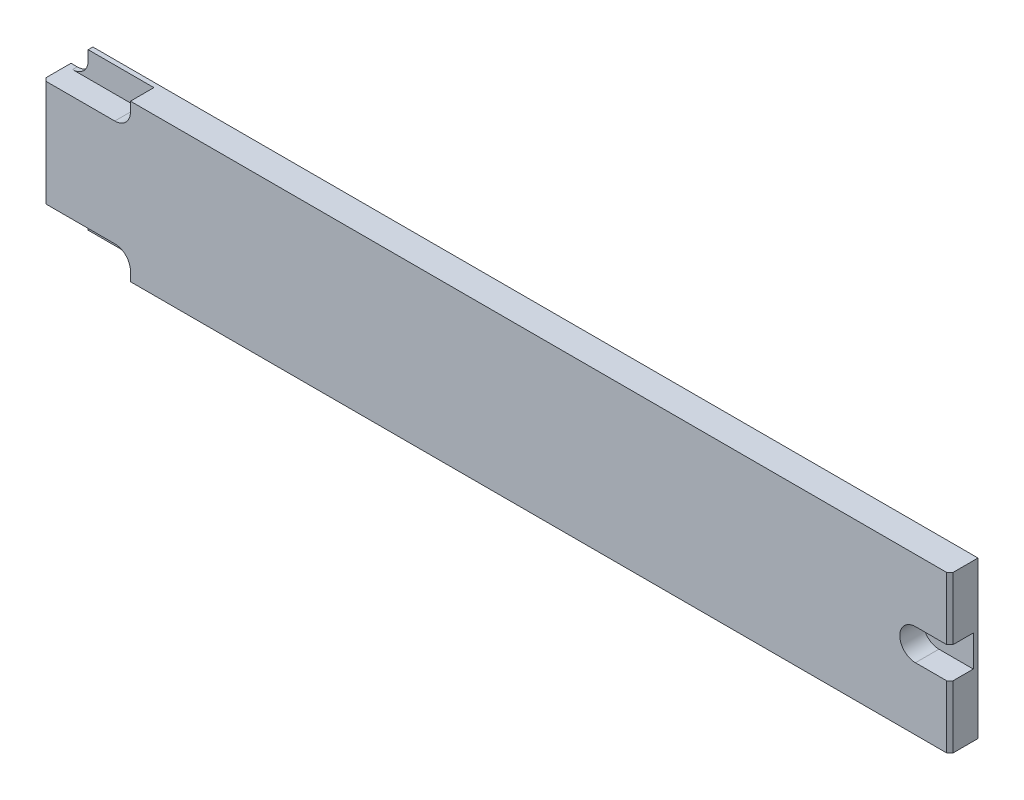
from build123d import *

# Parameters (mm, degrees)
BASE_EXTRUDE_DEPTH = 9
CUT_EXTRUDE1_DEPTH = 7.5
CHAMFER1_SIZE      = 1


with BuildPart() as part:
    # Sketch1 → Base-Extrude (new body)
    with BuildSketch(Plane.XY):
        with BuildLine():
            Line((7, 0), (290, 0))
            Line((290, 0), (290, 50))
            Line((290, 50), (7, 50))
            Line((7, 50), (7, 47))
            ThreePointArc((7, 47), (5.535533906, 43.464466094), (2, 42))
            Line((2, 42), (0, 42))
            Line((0, 42), (0, 8))
            Line((0, 8), (2, 8))
            ThreePointArc((2, 8), (5.535533906, 6.535533906), (7, 3))
            Line((7, 3), (7, 0))
        make_face()
    extrude(amount=BASE_EXTRUDE_DEPTH)

    # Sketch2 → Cut-Extrude1 (cut)
    with BuildSketch(Plane.XY.offset(9)):
        with BuildLine():
            Line((2, 8), (23, 8))
            ThreePointArc((23, 8), (26.535533906, 6.535533906), (28, 3))
            Line((28, 3), (28, 0))
            Line((28, 0), (2, 0))
            Line((2, 0), (2, 8))
        make_face()
        with BuildLine():
            Line((279, 30), (290, 30))
            Line((290, 30), (290, 20))
            Line((290, 20), (279, 20))
            ThreePointArc((279, 20), (274, 25), (279, 30))
        make_face()
        with BuildLine():
            Line((28, 47), (28, 50))
            Line((28, 50), (2, 50))
            Line((2, 50), (2, 42))
            Line((2, 42), (23, 42))
            ThreePointArc((23, 42), (26.535533906, 43.464466094), (28, 47))
        make_face()
    extrude(amount=-CUT_EXTRUDE1_DEPTH, mode=Mode.SUBTRACT)

    # Chamfer1
    chamfer1_edges = [part.edges().sort_by_distance(p)[0] for p in [
        (0, 25, 9),
        (290, 40, 9),
        (290, 10, 9),
    ]]
    chamfer(chamfer1_edges, length=CHAMFER1_SIZE)


solid = part.part
